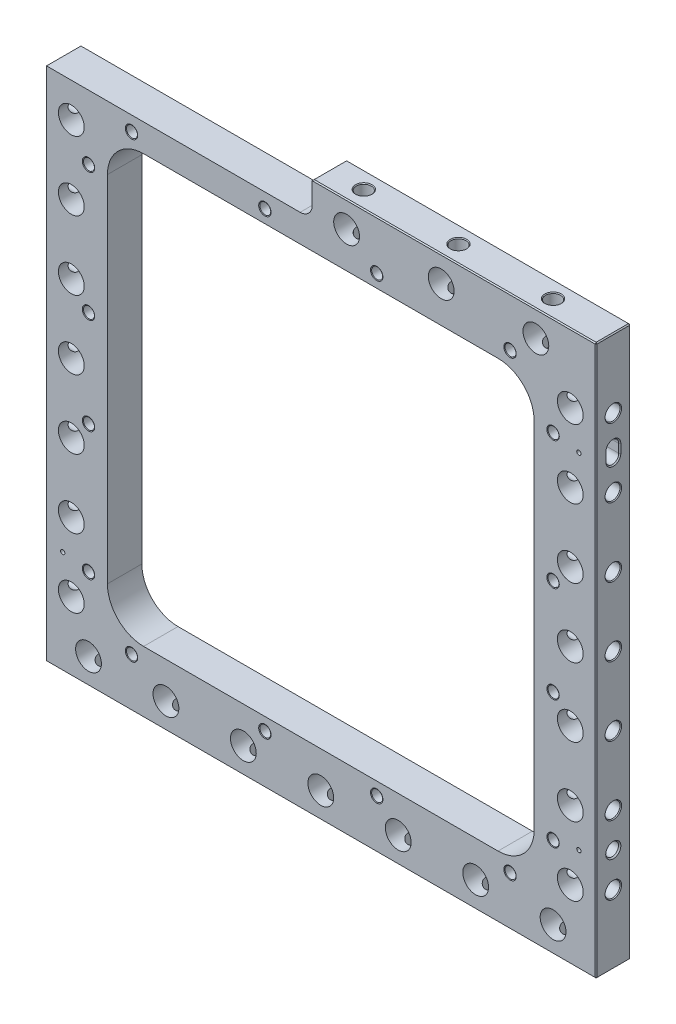
from build123d import *

# Parameters (mm, degrees)
EXTRUDE1_DEPTH                               = 12.7
F_3_4_0_75_DIAMETER_HOLE1_D                  = 19.05
LPATTERN1_COUNT                              = 4
LPATTERN1_PITCH                              = 50.8
LPATTERN1_COL_COUNT                          = 4
LPATTERN1_COL_PITCH                          = 50.8
F_3_4_0_75_DIAMETER_HOLE3_D                  = 19.05
LPATTERN2_COUNT                              = 4
LPATTERN2_PITCH                              = 57.15
LPATTERN2_COL_COUNT                          = 4
LPATTERN2_COL_PITCH                          = 57.15
LPATTERN3_COUNT                              = 3
LPATTERN3_PITCH                              = 69.85
SKETCH18_W                                   = 314.96
SKETCH18_H                                   = 314.96
CUT_EXTRUDE1_DEPTH                           = 26.4000001
FILLET1_R                                    = 26.67
FILLET2_R                                    = 8.89
TAPPED_HOLE_FOR_1_4_20_HELICOIL1_AT_2_COUNT  = 2
TAPPED_HOLE_FOR_1_4_20_HELICOIL1_AT_2_PITCH  = 98.425
TAPPED_HOLE_FOR_1_4_20_HELICOIL1_AT_3_COUNT  = 2
TAPPED_HOLE_FOR_1_4_20_HELICOIL1_AT_3_PITCH  = 180.975
TAPPED_HOLE_FOR_1_4_20_HELICOIL1_AT_4_COUNT  = 2
TAPPED_HOLE_FOR_1_4_20_HELICOIL1_AT_4_PITCH  = 279.4
TAPPED_HOLE_FOR_1_4_20_HELICOIL1_AT_5_COUNT  = 2
TAPPED_HOLE_FOR_1_4_20_HELICOIL1_AT_5_PITCH  = 48.626241886
TAPPED_HOLE_FOR_1_4_20_HELICOIL1_AT_6_COUNT  = 2
TAPPED_HOLE_FOR_1_4_20_HELICOIL1_AT_6_PITCH  = 135.225184507
TAPPED_HOLE_FOR_1_4_20_HELICOIL1_AT_7_COUNT  = 2
TAPPED_HOLE_FOR_1_4_20_HELICOIL1_AT_7_PITCH  = 205.038147
TAPPED_HOLE_FOR_1_4_20_HELICOIL1_AT_8_COUNT  = 2
TAPPED_HOLE_FOR_1_4_20_HELICOIL1_AT_8_PITCH  = 298.871234648
TAPPED_HOLE_FOR_1_4_20_HELICOIL1_AT_9_COUNT  = 2
TAPPED_HOLE_FOR_1_4_20_HELICOIL1_AT_9_PITCH  = 334.01
TAPPED_HOLE_FOR_1_4_20_HELICOIL1_AT_10_COUNT = 2
TAPPED_HOLE_FOR_1_4_20_HELICOIL1_AT_10_PITCH = 348.209937717
TAPPED_HOLE_FOR_1_4_20_HELICOIL1_AT_11_COUNT = 2
TAPPED_HOLE_FOR_1_4_20_HELICOIL1_AT_11_PITCH = 379.8876554
TAPPED_HOLE_FOR_1_4_20_HELICOIL1_AT_12_COUNT = 2
TAPPED_HOLE_FOR_1_4_20_HELICOIL1_AT_12_PITCH = 435.461869858
TAPPED_HOLE_FOR_1_4_20_HELICOIL1_AT_13_COUNT = 2
TAPPED_HOLE_FOR_1_4_20_HELICOIL1_AT_13_PITCH = 430.267678196
TAPPED_HOLE_FOR_1_4_20_HELICOIL1_AT_14_COUNT = 2
TAPPED_HOLE_FOR_1_4_20_HELICOIL1_AT_14_PITCH = 371.277391885
TAPPED_HOLE_FOR_1_4_20_HELICOIL1_AT_15_COUNT = 2
TAPPED_HOLE_FOR_1_4_20_HELICOIL1_AT_15_PITCH = 337.775236696
TAPPED_HOLE_FOR_1_4_20_HELICOIL1_AT_16_COUNT = 2
TAPPED_HOLE_FOR_1_4_20_HELICOIL1_AT_16_PITCH = 313.322152744
CUT_EXTRUDE2_DEPTH                           = 15.24
CHAMFER1_SIZE                                = 0.762
F_1_8_0_125_DIAMETER_HOLE1_D                 = 3.175
F_1_8_0_125_DIAMETER_HOLE1_DEPTH             = 9.652
F_1_8_0_125_DIAMETER_HOLE1_TIP               = 0.953866233
CHAMFER2_SIZE                                = 0.762


with BuildPart() as part:
    # Sketch1 → Extrude1 (new body, symmetric)
    with BuildSketch(Plane.XY):
        Polygon((-203.2, 177.8), (-203.2, -203.2), (203.2, -203.2), (203.2, 203.2), (-6.35, 203.2), (-6.35, 177.8), align=None)
    extrude(amount=EXTRUDE1_DEPTH, both=True)

    # 3/4 (0.75) Diameter Hole1 (through all)
    with Locations(Plane.XY.offset(12.7)):
        with Locations((184.15, 0), (-184.15, 0)):
            f_3_4_0_75_diameter_hole1 = Hole(F_3_4_0_75_DIAMETER_HOLE1_D / 2)

    # Sketch5 → 7/16 (0.4375) Diameter Hole1 (revolve, cut)
    with BuildSketch(Plane(origin=(203.2, 0, 0), x_dir=(0, 0, -1), z_dir=(0, 1, 0))):
        Polygon((0, 0), (0, 38.263531814), (5.55625, 34.925), (5.55625, 0.620911348), (6.096, 0), align=None)
    f_7_16_0_4375_diameter_hole1 = revolve(axis=Axis((209.55, 0, 0), (-1, 0, 0)), mode=Mode.SUBTRACT)

    # Sketch7 → 7/16 (0.4375) Diameter Hole2 (revolve, cut)
    with BuildSketch(Plane(origin=(-203.2, 0, 0), x_dir=(0, 0, 1), z_dir=(0, 1, 0))):
        Polygon((0, 0), (0, 38.263531814), (5.55625, 34.925), (5.55625, 0.620911348), (6.096, 0), align=None)
    f_7_16_0_4375_diameter_hole2 = revolve(axis=Axis((-209.55, 0, 0), (1, 0, 0)), mode=Mode.SUBTRACT)

    # LPattern1: 3/4 (0.75) Diameter Hole1, 7/16 (0.4375) Diameter Hole1, 7/16 (0.4375) Diameter Hole2 ×4
    with Locations(*[(0, -i * LPATTERN1_PITCH, 0) for i in range(1, LPATTERN1_COUNT)]):
        add(f_3_4_0_75_diameter_hole1, mode=Mode.SUBTRACT)
        add(f_7_16_0_4375_diameter_hole1, mode=Mode.SUBTRACT)
        add(f_7_16_0_4375_diameter_hole2, mode=Mode.SUBTRACT)

    # LPattern1 col: 3/4 (0.75) Diameter Hole1, 7/16 (0.4375) Diameter Hole1, 7/16 (0.4375) Diameter Hole2 ×4
    with Locations(*[(0, i * LPATTERN1_COL_PITCH, 0) for i in range(1, LPATTERN1_COL_COUNT)]):
        add(f_3_4_0_75_diameter_hole1, mode=Mode.SUBTRACT)
        add(f_7_16_0_4375_diameter_hole1, mode=Mode.SUBTRACT)
        add(f_7_16_0_4375_diameter_hole2, mode=Mode.SUBTRACT)

    # Sketch9 → 3/4 (0.75) Diameter Hole2 (revolve, cut)
    with BuildSketch(Plane(origin=(0, -184.15, 12.7), x_dir=(0, -1, 0), z_dir=(1, 0, 0))):
        Polygon((0, 0), (0, 40.648197396), (9.525, 34.925), (9.525, 0), align=None)
    f_3_4_0_75_diameter_hole2 = revolve(axis=Axis((0, -184.15, 19.05), (0, 0, -1)), mode=Mode.SUBTRACT)

    # Sketch11 → 7/16 (0.4375) Diameter Hole3 (revolve, cut)
    with BuildSketch(Plane(origin=(0, -203.2, 0), x_dir=(0, 0, -1), z_dir=(1, 0, 0))):
        Polygon((0, 0), (0, 38.263531814), (5.55625, 34.925), (5.55625, 0.620911348), (6.096, 0), align=None)
    f_7_16_0_4375_diameter_hole3 = revolve(axis=Axis((0, -209.55, 0), (0, 1, 0)), mode=Mode.SUBTRACT)

    # 3/4 (0.75) Diameter Hole3 (through all)
    with Locations(Plane.XY.offset(12.7)):
        with Locations((19.05, 184.15)):
            f_3_4_0_75_diameter_hole3 = Hole(F_3_4_0_75_DIAMETER_HOLE3_D / 2)

    # Sketch13 → 7/16 (0.4375) Diameter Hole4 (revolve, cut)
    with BuildSketch(Plane(origin=(19.05, 203.2, 0), x_dir=(0, 0, 1), z_dir=(1, 0, 0))):
        Polygon((0, 0), (0, 38.263531814), (5.55625, 34.925), (5.55625, 0.620911348), (6.096, 0), align=None)
    f_7_16_0_4375_diameter_hole4 = revolve(axis=Axis((19.05, 209.55, 0), (0, -1, 0)), mode=Mode.SUBTRACT)

    # LPattern2: 3/4 (0.75) Diameter Hole2, 7/16 (0.4375) Diameter Hole3 ×4
    with Locations(*[(-i * LPATTERN2_PITCH, 0, 0) for i in range(1, LPATTERN2_COUNT)]):
        add(f_3_4_0_75_diameter_hole2, mode=Mode.SUBTRACT)
        add(f_7_16_0_4375_diameter_hole3, mode=Mode.SUBTRACT)

    # LPattern2 col: 3/4 (0.75) Diameter Hole2, 7/16 (0.4375) Diameter Hole3 ×4
    with Locations(*[(i * LPATTERN2_COL_PITCH, 0, 0) for i in range(1, LPATTERN2_COL_COUNT)]):
        add(f_3_4_0_75_diameter_hole2, mode=Mode.SUBTRACT)
        add(f_7_16_0_4375_diameter_hole3, mode=Mode.SUBTRACT)

    # LPattern3: 3/4 (0.75) Diameter Hole3, 7/16 (0.4375) Diameter Hole4 ×3
    with Locations(*[(i * LPATTERN3_PITCH, 0, 0) for i in range(1, LPATTERN3_COUNT)]):
        add(f_3_4_0_75_diameter_hole3, mode=Mode.SUBTRACT)
        add(f_7_16_0_4375_diameter_hole4, mode=Mode.SUBTRACT)

    # Sketch18 → Cut-Extrude1 (cut, through all)
    with BuildSketch(Plane.XY.offset(12.7)):
        Rectangle(SKETCH18_W, SKETCH18_H)
    extrude(amount=-CUT_EXTRUDE1_DEPTH, mode=Mode.SUBTRACT)

    # Fillet1
    fillet1_edges = [part.edges().sort_by_distance(p)[0] for p in [
        (157.48, 157.48, 0),
        (157.48, -157.48, 0),
        (-157.48, -157.48, 0),
        (-157.48, 157.48, 0),
    ]]
    fillet(fillet1_edges, radius=FILLET1_R)

    # Fillet2
    fillet2_edges = [part.edges().sort_by_distance(p)[0] for p in [
        (-6.35, 177.8, 0),
    ]]
    fillet(fillet2_edges, radius=FILLET2_R)

    # Sketch19 → Tapped Hole for 1/4-20 Helicoil1 (revolve, cut)
    with BuildSketch(Plane(origin=(-139.7, 167.005, 12.7), x_dir=(0, -1, 0), z_dir=(1, 0, 0))):
        Polygon((0, 0), (0, 25.4), (3.3782, 25.4), (3.3782, 15.7226), (4.04749, 15.7226), (4.04749, 0.30282599), (4.572, 0), align=None)
    tapped_hole_for_1_4_20_helicoil1 = revolve(axis=Axis((-139.7, 167.005, 19.05), (0, 0, -1)), mode=Mode.SUBTRACT)

    # Tapped Hole for 1/4-20 Helicoil1 at 2: Tapped Hole for 1/4-20 Helicoil1 ×2
    with Locations(*[(i * TAPPED_HOLE_FOR_1_4_20_HELICOIL1_AT_2_PITCH, 0, 0) for i in range(1, TAPPED_HOLE_FOR_1_4_20_HELICOIL1_AT_2_COUNT)]):
        add(tapped_hole_for_1_4_20_helicoil1, mode=Mode.SUBTRACT)

    # Tapped Hole for 1/4-20 Helicoil1 at 3: Tapped Hole for 1/4-20 Helicoil1 ×2
    with Locations(*[(i * TAPPED_HOLE_FOR_1_4_20_HELICOIL1_AT_3_PITCH, 0, 0) for i in range(1, TAPPED_HOLE_FOR_1_4_20_HELICOIL1_AT_3_COUNT)]):
        add(tapped_hole_for_1_4_20_helicoil1, mode=Mode.SUBTRACT)

    # Tapped Hole for 1/4-20 Helicoil1 at 4: Tapped Hole for 1/4-20 Helicoil1 ×2
    with Locations(*[(i * TAPPED_HOLE_FOR_1_4_20_HELICOIL1_AT_4_PITCH, 0, 0) for i in range(1, TAPPED_HOLE_FOR_1_4_20_HELICOIL1_AT_4_COUNT)]):
        add(tapped_hole_for_1_4_20_helicoil1, mode=Mode.SUBTRACT)

    # Tapped Hole for 1/4-20 Helicoil1 at 5: Tapped Hole for 1/4-20 Helicoil1 ×2
    with Locations(*[Vector(-0.652939622, -0.757409962, 0) * (i * TAPPED_HOLE_FOR_1_4_20_HELICOIL1_AT_5_PITCH) for i in range(1, TAPPED_HOLE_FOR_1_4_20_HELICOIL1_AT_5_COUNT)]):
        add(tapped_hole_for_1_4_20_helicoil1, mode=Mode.SUBTRACT)

    # Tapped Hole for 1/4-20 Helicoil1 at 6: Tapped Hole for 1/4-20 Helicoil1 ×2
    with Locations(*[Vector(-0.234793542, -0.972045263, 0) * (i * TAPPED_HOLE_FOR_1_4_20_HELICOIL1_AT_6_PITCH) for i in range(1, TAPPED_HOLE_FOR_1_4_20_HELICOIL1_AT_6_COUNT)]):
        add(tapped_hole_for_1_4_20_helicoil1, mode=Mode.SUBTRACT)

    # Tapped Hole for 1/4-20 Helicoil1 at 7: Tapped Hole for 1/4-20 Helicoil1 ×2
    with Locations(*[Vector(-0.154849234, -0.987938113, 0) * (i * TAPPED_HOLE_FOR_1_4_20_HELICOIL1_AT_7_PITCH) for i in range(1, TAPPED_HOLE_FOR_1_4_20_HELICOIL1_AT_7_COUNT)]):
        add(tapped_hole_for_1_4_20_helicoil1, mode=Mode.SUBTRACT)

    # Tapped Hole for 1/4-20 Helicoil1 at 8: Tapped Hole for 1/4-20 Helicoil1 ×2
    with Locations(*[Vector(-0.106233041, -0.99434126, 0) * (i * TAPPED_HOLE_FOR_1_4_20_HELICOIL1_AT_8_PITCH) for i in range(1, TAPPED_HOLE_FOR_1_4_20_HELICOIL1_AT_8_COUNT)]):
        add(tapped_hole_for_1_4_20_helicoil1, mode=Mode.SUBTRACT)

    # Tapped Hole for 1/4-20 Helicoil1 at 9: Tapped Hole for 1/4-20 Helicoil1 ×2
    with Locations(*[(0, -i * TAPPED_HOLE_FOR_1_4_20_HELICOIL1_AT_9_PITCH, 0) for i in range(1, TAPPED_HOLE_FOR_1_4_20_HELICOIL1_AT_9_COUNT)]):
        add(tapped_hole_for_1_4_20_helicoil1, mode=Mode.SUBTRACT)

    # Tapped Hole for 1/4-20 Helicoil1 at 10: Tapped Hole for 1/4-20 Helicoil1 ×2
    with Locations(*[Vector(0.28265994, -0.959220182, 0) * (i * TAPPED_HOLE_FOR_1_4_20_HELICOIL1_AT_10_PITCH) for i in range(1, TAPPED_HOLE_FOR_1_4_20_HELICOIL1_AT_10_COUNT)]):
        add(tapped_hole_for_1_4_20_helicoil1, mode=Mode.SUBTRACT)

    # Tapped Hole for 1/4-20 Helicoil1 at 11: Tapped Hole for 1/4-20 Helicoil1 ×2
    with Locations(*[Vector(0.476390842, -0.879233624, 0) * (i * TAPPED_HOLE_FOR_1_4_20_HELICOIL1_AT_11_PITCH) for i in range(1, TAPPED_HOLE_FOR_1_4_20_HELICOIL1_AT_11_COUNT)]):
        add(tapped_hole_for_1_4_20_helicoil1, mode=Mode.SUBTRACT)

    # Tapped Hole for 1/4-20 Helicoil1 at 12: Tapped Hole for 1/4-20 Helicoil1 ×2
    with Locations(*[Vector(0.6416176, -0.767024677, 0) * (i * TAPPED_HOLE_FOR_1_4_20_HELICOIL1_AT_12_PITCH) for i in range(1, TAPPED_HOLE_FOR_1_4_20_HELICOIL1_AT_12_COUNT)]):
        add(tapped_hole_for_1_4_20_helicoil1, mode=Mode.SUBTRACT)

    # Tapped Hole for 1/4-20 Helicoil1 at 13: Tapped Hole for 1/4-20 Helicoil1 ×2
    with Locations(*[Vector(0.723154482, -0.690686322, 0) * (i * TAPPED_HOLE_FOR_1_4_20_HELICOIL1_AT_13_PITCH) for i in range(1, TAPPED_HOLE_FOR_1_4_20_HELICOIL1_AT_13_COUNT)]):
        add(tapped_hole_for_1_4_20_helicoil1, mode=Mode.SUBTRACT)

    # Tapped Hole for 1/4-20 Helicoil1 at 14: Tapped Hole for 1/4-20 Helicoil1 ×2
    with Locations(*[Vector(0.838052644, -0.545589374, 0) * (i * TAPPED_HOLE_FOR_1_4_20_HELICOIL1_AT_14_PITCH) for i in range(1, TAPPED_HOLE_FOR_1_4_20_HELICOIL1_AT_14_COUNT)]):
        add(tapped_hole_for_1_4_20_helicoil1, mode=Mode.SUBTRACT)

    # Tapped Hole for 1/4-20 Helicoil1 at 15: Tapped Hole for 1/4-20 Helicoil1 ×2
    with Locations(*[Vector(0.921174693, -0.389149309, 0) * (i * TAPPED_HOLE_FOR_1_4_20_HELICOIL1_AT_15_PITCH) for i in range(1, TAPPED_HOLE_FOR_1_4_20_HELICOIL1_AT_15_COUNT)]):
        add(tapped_hole_for_1_4_20_helicoil1, mode=Mode.SUBTRACT)

    # Tapped Hole for 1/4-20 Helicoil1 at 16: Tapped Hole for 1/4-20 Helicoil1 ×2
    with Locations(*[Vector(0.99306735, -0.117546748, 0) * (i * TAPPED_HOLE_FOR_1_4_20_HELICOIL1_AT_16_PITCH) for i in range(1, TAPPED_HOLE_FOR_1_4_20_HELICOIL1_AT_16_COUNT)]):
        add(tapped_hole_for_1_4_20_helicoil1, mode=Mode.SUBTRACT)

    # Sketch23 → 3/8 (0.376) Pin Locate1 (revolve, cut)
    with BuildSketch(Plane(origin=(203.2, -127, 0), x_dir=(0, 0, -1), z_dir=(0, 1, 0))):
        Polygon((0, 0), (0, 18.109229628), (4.7752, 15.24), (4.7752, 0.935019441), (5.588, 0), align=None)
    f_3_8_0_376_pin_locate1 = revolve(axis=Axis((209.55, -127, 0), (-1, 0, 0)), mode=Mode.SUBTRACT)

    # Sketch27 → Cut-Extrude2 (cut)
    with BuildSketch(Plane(origin=(203.2, 0, 0), x_dir=(0, 0, -1), z_dir=(1, 0, 0))):
        with BuildLine():
            Line((4.7752, 123.825), (4.7752, 130.175))
            ThreePointArc((4.7752, 130.175), (0, 134.9502), (-4.7752, 130.175))
            Line((-4.7752, 130.175), (-4.7752, 123.825))
            ThreePointArc((-4.7752, 123.825), (0, 119.0498), (4.7752, 123.825))
        make_face()
    extrude(amount=-CUT_EXTRUDE2_DEPTH, mode=Mode.SUBTRACT)

    # Chamfer1
    chamfer1_edges = [part.edges().sort_by_distance(p)[0] for p in [
        (203.2, 119.0498, 0),
        (203.2, 127, -4.7752),
        (203.2, 134.9502, 0),
        (203.2, 127, 4.7752),
    ]]
    chamfer(chamfer1_edges, length=CHAMFER1_SIZE)

    # Mirror1: 3/8 (0.376) Pin Locate1 across plane
    add(f_3_8_0_376_pin_locate1.mirror(Plane(origin=(0, 0, 0), x_dir=(0, 0, 1), z_dir=(1, 0, 0))), mode=Mode.SUBTRACT)

    # 1/8 (0.125) Diameter Hole1
    with Locations(Plane(origin=(1.942061067, 0.007556206, 12.7), x_dir=(-1, 0, 0), z_dir=(0, 0, 1))):
        with Locations((-188.557938933, 127.007556206), (-188.557938933, -126.992443794), (192.442061067, 127.007556206)):
            Hole(F_1_8_0_125_DIAMETER_HOLE1_D / 2, depth=F_1_8_0_125_DIAMETER_HOLE1_DEPTH)
            with Locations((0, 0, -(F_1_8_0_125_DIAMETER_HOLE1_DEPTH + F_1_8_0_125_DIAMETER_HOLE1_TIP / 2))):  # 118° drill point
                Cone(0, F_1_8_0_125_DIAMETER_HOLE1_D / 2, F_1_8_0_125_DIAMETER_HOLE1_TIP, mode=Mode.SUBTRACT)

    # Chamfer2
    chamfer2_edges = [part.edges().sort_by_distance(p)[0] for p in [
        (0, -203.2, 12.7),
        (-6.35, 203.2, 0),
        (203.2, 203.2, 0),
        (203.2, -203.2, 0),
        (-203.2, -203.2, 0),
        (-203.2, 177.8, 0),
        (203.2, 0, 12.7),
        (98.425, 203.2, 12.7),
        (98.425, 203.2, -12.7),
        (203.2, 0, -12.7),
        (-203.2, -12.7, 12.7),
        (0, -203.2, -12.7),
        (-203.2, -12.7, -12.7),
    ]]
    chamfer(chamfer2_edges, length=CHAMFER2_SIZE)


solid = part.part
